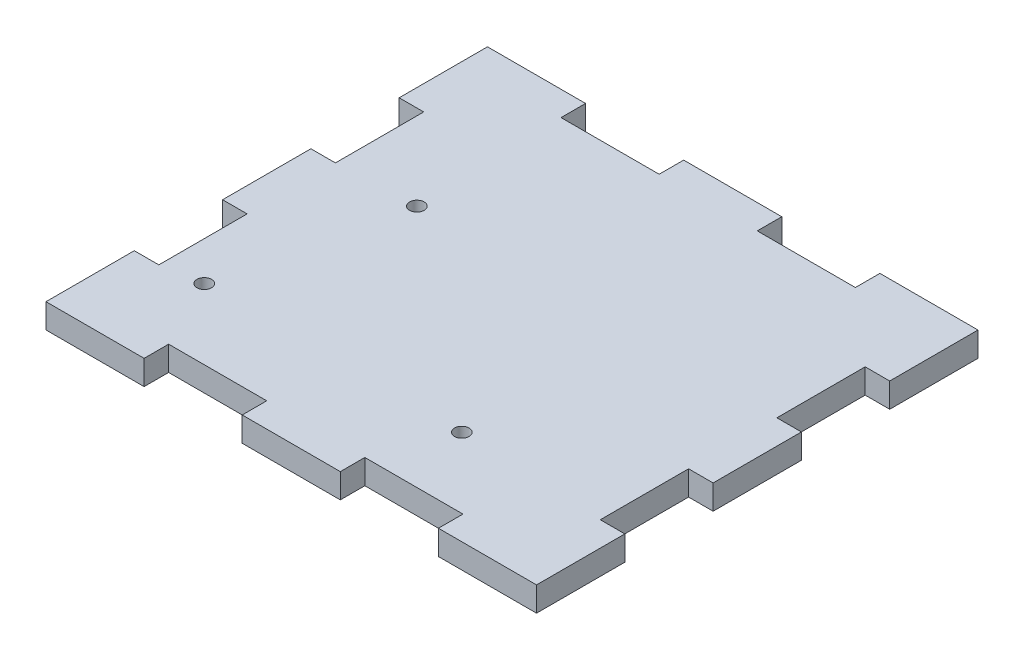
from build123d import *

# Parameters (mm, degrees)
SKETCH1_W           = 127
SKETCH1_H           = 114.3
BOSS_EXTRUDE1_DEPTH = 6.35
SKETCH2_W           = 6.35
SKETCH2_H           = 22.86
SKETCH2_W_2         = 25.4
SKETCH2_H_2         = 6.35
CUT_EXTRUDE1_DEPTH  = 7.35
SKETCH3_R           = 1.89865
CUT_EXTRUDE2_DEPTH  = 7.35
SKETCH4_R           = 1.89865
CUT_EXTRUDE3_DEPTH  = 7.35


with BuildPart() as part:
    # Sketch1 → Boss-Extrude1 (new body)
    with BuildSketch(Plane(origin=(0, 0, 0), x_dir=(1, 0, 0), z_dir=(0, 1, 0))):
        Rectangle(SKETCH1_W, SKETCH1_H)
    extrude(amount=BOSS_EXTRUDE1_DEPTH)

    # Sketch2 → Cut-Extrude1 (cut, through all)
    with BuildSketch(Plane(origin=(0, 6.35, 0), x_dir=(1, 0, 0), z_dir=(0, 1, 0))):
        with Locations((-60.325, -22.86)):
            Rectangle(SKETCH2_W, SKETCH2_H)
        with Locations((-60.325, 22.86)):
            Rectangle(SKETCH2_W, SKETCH2_H)
        with Locations((-25.4, 53.975)):
            Rectangle(SKETCH2_W_2, SKETCH2_H_2)
        with Locations((25.4, 53.975)):
            Rectangle(SKETCH2_W_2, SKETCH2_H_2)
        with Locations((60.325, 22.86)):
            Rectangle(SKETCH2_W, SKETCH2_H)
        with Locations((60.325, -22.86)):
            Rectangle(SKETCH2_W, SKETCH2_H)
        with Locations((25.4, -53.975)):
            Rectangle(SKETCH2_W_2, SKETCH2_H_2)
        with Locations((-25.4, -53.975)):
            Rectangle(SKETCH2_W_2, SKETCH2_H_2)
    extrude(amount=-CUT_EXTRUDE1_DEPTH, mode=Mode.SUBTRACT)

    # Sketch3 → Cut-Extrude2 (cut, through all)
    with BuildSketch(Plane(origin=(0, 6.35, 0), x_dir=(1, 0, 0), z_dir=(0, 1, 0))):
        with Locations((-47.076322948, -32.600738686)):
            Circle(SKETCH3_R)
        with Locations((19.598677052, -32.600738686)):
            Circle(SKETCH3_R)
    extrude(amount=-CUT_EXTRUDE2_DEPTH, mode=Mode.SUBTRACT)

    # Sketch4 → Cut-Extrude3 (cut, through all)
    with BuildSketch(Plane.XZ):
        with Locations((-36.916322948, -12.280738686)):
            Circle(SKETCH4_R)
    extrude(amount=-CUT_EXTRUDE3_DEPTH, mode=Mode.SUBTRACT)


solid = part.part
